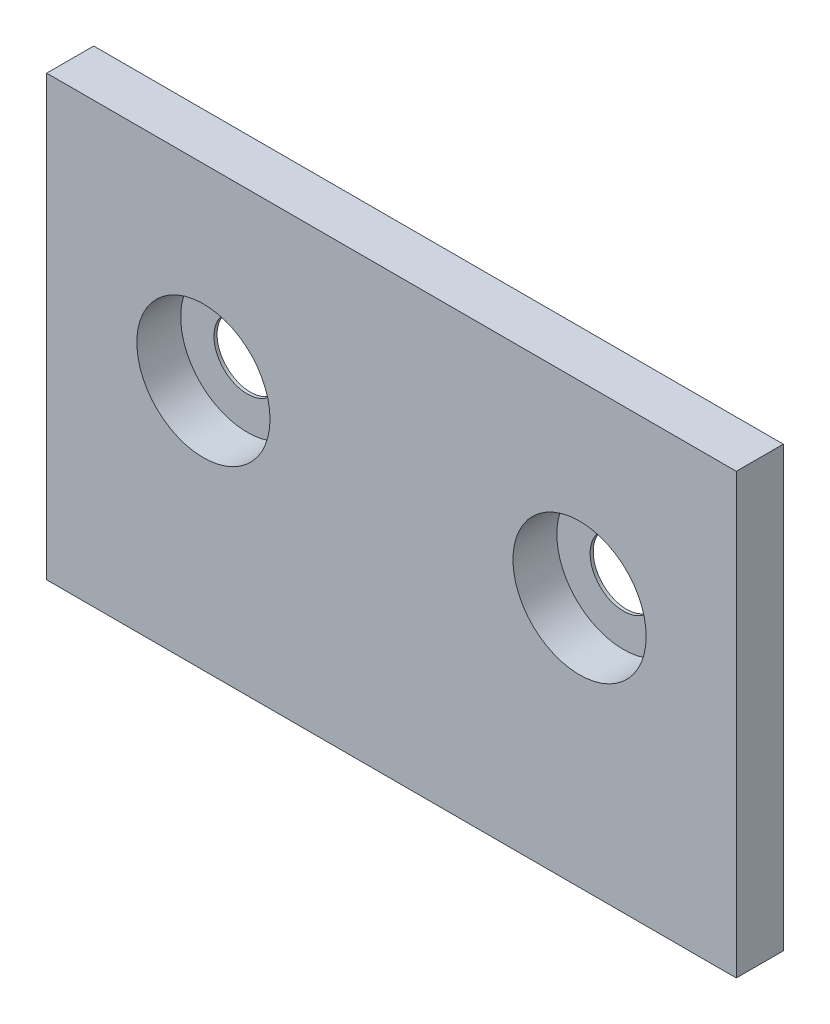
from build123d import *

# Parameters (mm, degrees)
SKETCH1_W                                         = 69.85
SKETCH1_H                                         = 44.45
EXTRUDE1_DEPTH                                    = 4.7625
CBORE_FOR_1_4_PAN_HEAD_MACHINE_SCREW1_D           = 6.7564
CBORE_FOR_1_4_PAN_HEAD_MACHINE_SCREW1_CBORE_D     = 13.49248
CBORE_FOR_1_4_PAN_HEAD_MACHINE_SCREW1_CBORE_DEPTH = 4.445


with BuildPart() as part:
    # Sketch1 → Extrude1 (new body)
    with BuildSketch(Plane.XY):
        with Locations((0, 61.9125)):
            Rectangle(SKETCH1_W, SKETCH1_H)
    extrude(amount=EXTRUDE1_DEPTH)

    # CBORE for 1/4 Pan Head Machine Screw1 (through all)
    with Locations(Plane.XY.offset(4.7625)):
        with Locations((-19.05, 65.0875), (19.05, 65.0875)):
            CounterBoreHole(CBORE_FOR_1_4_PAN_HEAD_MACHINE_SCREW1_D / 2, CBORE_FOR_1_4_PAN_HEAD_MACHINE_SCREW1_CBORE_D / 2, CBORE_FOR_1_4_PAN_HEAD_MACHINE_SCREW1_CBORE_DEPTH)


solid = part.part
